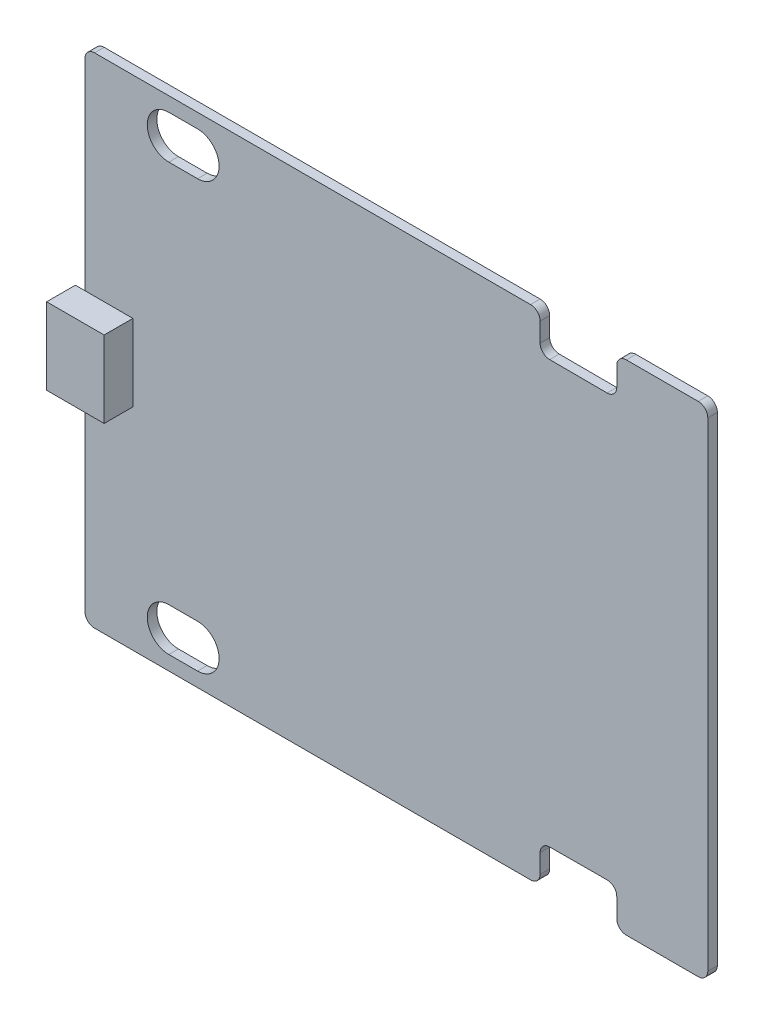
from build123d import *

# Parameters (mm, degrees)
EXTRUDE_1_DEPTH = 1
FILLET_1_R      = 1
SKETCH_2_W      = 6
SKETCH_2_H      = 8
EXTRUDE_2_DEPTH = 3


with BuildPart() as part:
    # Эскиз1 → Бобышка-Вытянуть1 (new body)
    with BuildSketch(Plane.XY):
        Polygon((23, -22), (23, -26), (32.5, -26), (32.5, 26), (23, 26), (23, 22), (15, 22.030768978), (15, 26), (-32.5, 26), (-32.5, -26), (15, -26), (15, -22.030768978), align=None)
        with BuildLine():
            ThreePointArc((-20.75, 20), (-18.5, 22.25), (-20.75, 24.5))
            Line((-20.75, 24.5), (-23.75, 24.5))
            ThreePointArc((-23.75, 24.5), (-26, 22.25), (-23.75, 20))
            Line((-23.75, 20), (-20.75, 20))
        make_face(mode=Mode.SUBTRACT)
        with BuildLine():
            Line((-23.75, -20), (-20.75, -20))
            ThreePointArc((-20.75, -20), (-18.5, -22.25), (-20.75, -24.5))
            Line((-20.75, -24.5), (-23.75, -24.5))
            ThreePointArc((-23.75, -24.5), (-26, -22.25), (-23.75, -20))
        make_face(mode=Mode.SUBTRACT)
    extrude(amount=EXTRUDE_1_DEPTH)

    # Скругление1
    fillet_1_edges = [part.edges().sort_by_distance(p)[0] for p in [
        (23, -22, 0.5),
        (15, -22.030768978, 0.5),
        (15, -26, 0.5),
        (-32.5, -26, 0.5),
        (-32.5, 26, 0.5),
        (15, 26, 0.5),
        (15, 22.030768978, 0.5),
        (23, 22, 0.5),
        (23, 26, 0.5),
        (32.5, 26, 0.5),
        (32.5, -26, 0.5),
        (23, -26, 0.5),
    ]]
    fillet(fillet_1_edges, radius=FILLET_1_R)

    # Эскиз2 → Бобышка-Вытянуть2 (add)
    with BuildSketch(Plane.XY.offset(1)):
        with Locations((-30.5, 0)):
            Rectangle(SKETCH_2_W, SKETCH_2_H)
    extrude(amount=EXTRUDE_2_DEPTH)


solid = part.part
